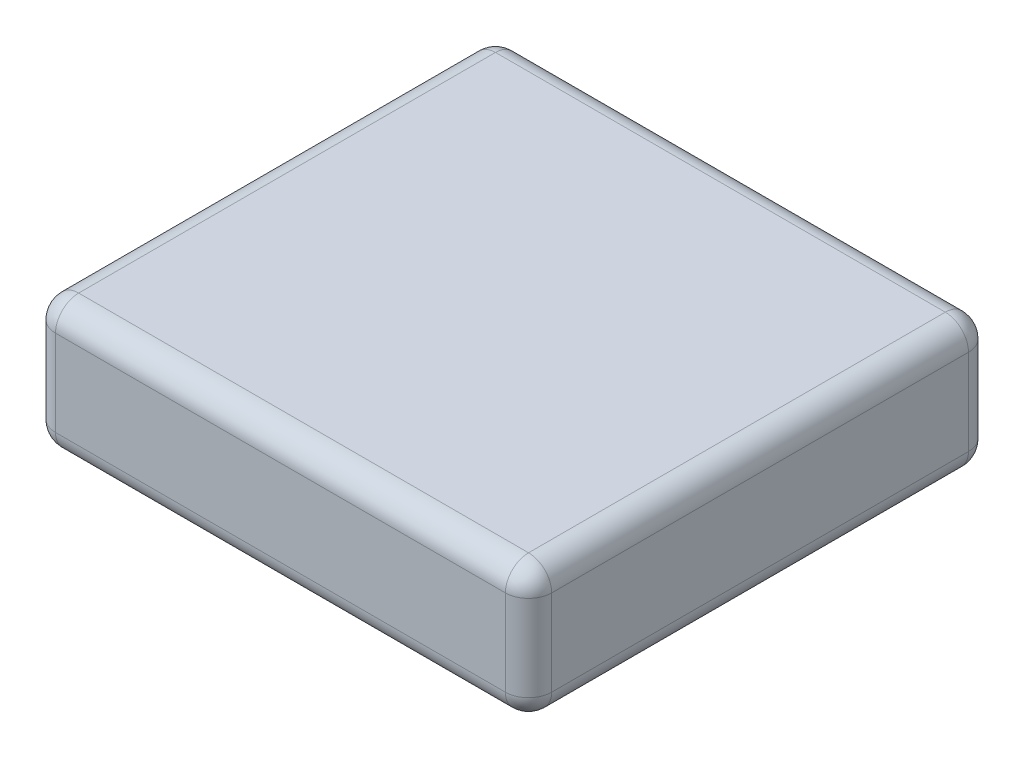
from build123d import *

# Parameters (mm, degrees)
SKETCH1_W           = 750
SKETCH1_H           = 700
BOSS_EXTRUDE1_DEPTH = 200
FILLET1_R           = 35


with BuildPart() as part:
    # Sketch1 → Boss-Extrude1 (new body)
    with BuildSketch(Plane(origin=(0, 0, 0), x_dir=(1, 0, 0), z_dir=(0, 1, 0))):
        with Locations((131.552706553, 0)):
            Rectangle(SKETCH1_W, SKETCH1_H)
    extrude(amount=BOSS_EXTRUDE1_DEPTH)

    # Fillet1
    fillet1_edges = [part.edges().sort_by_distance(p)[0] for p in [
        (-243.447293447, 200, 0),
        (131.552706553, 200, 350),
        (506.552706553, 200, 0),
        (131.552706553, 0, 350),
        (-243.447293447, 0, 0),
        (131.552706553, 0, -350),
        (506.552706553, 0, 0),
        (506.552706553, 100, 350),
        (-243.447293447, 100, 350),
        (-243.447293447, 100, -350),
        (506.552706553, 100, -350),
        (131.552706553, 200, -350),
    ]]
    fillet(fillet1_edges, radius=FILLET1_R)


solid = part.part
